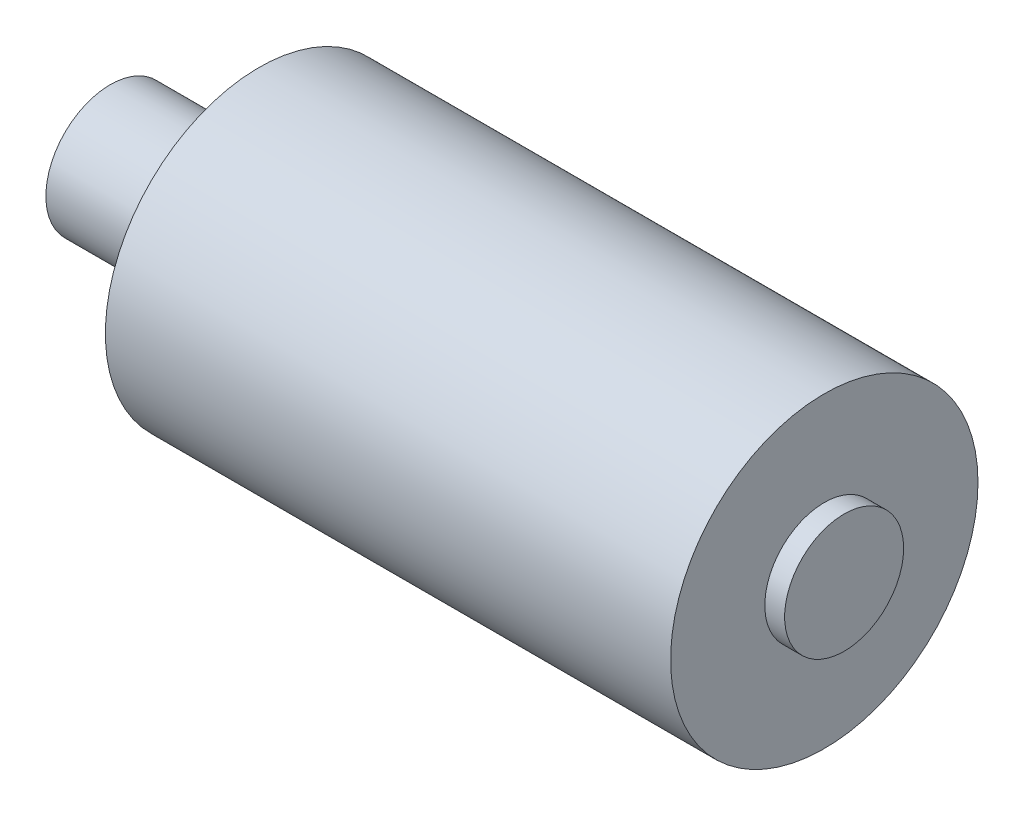
from build123d import *

# Parameters (mm, degrees)
SKETCH_1_R      = 15.5
EXTRUDE_1_DEPTH = 57
SKETCH_2_R      = 6.5
EXTRUDE_2_DEPTH = 15
SKETCH_3_R      = 6
EXTRUDE_3_DEPTH = 2


with BuildPart() as part:
    # 草图1 → 凸台-拉伸1 (new body)
    with BuildSketch(Plane(origin=(0, 0, 0), x_dir=(0, 0, -1), z_dir=(1, 0, 0))):
        Circle(SKETCH_1_R)
    extrude(amount=EXTRUDE_1_DEPTH)

    # 草图2 → 凸台-拉伸2 (add)
    with BuildSketch(Plane(origin=(0, 0, 0), x_dir=(0, 0, -1), z_dir=(1, 0, 0))):
        Circle(SKETCH_2_R)
    extrude(amount=-EXTRUDE_2_DEPTH)

    # 草图3 → 凸台-拉伸3 (add)
    with BuildSketch(Plane(origin=(57, 0, 0), x_dir=(0, 0, -1), z_dir=(1, 0, 0))):
        Circle(SKETCH_3_R)
    extrude(amount=EXTRUDE_3_DEPTH)


solid = part.part
